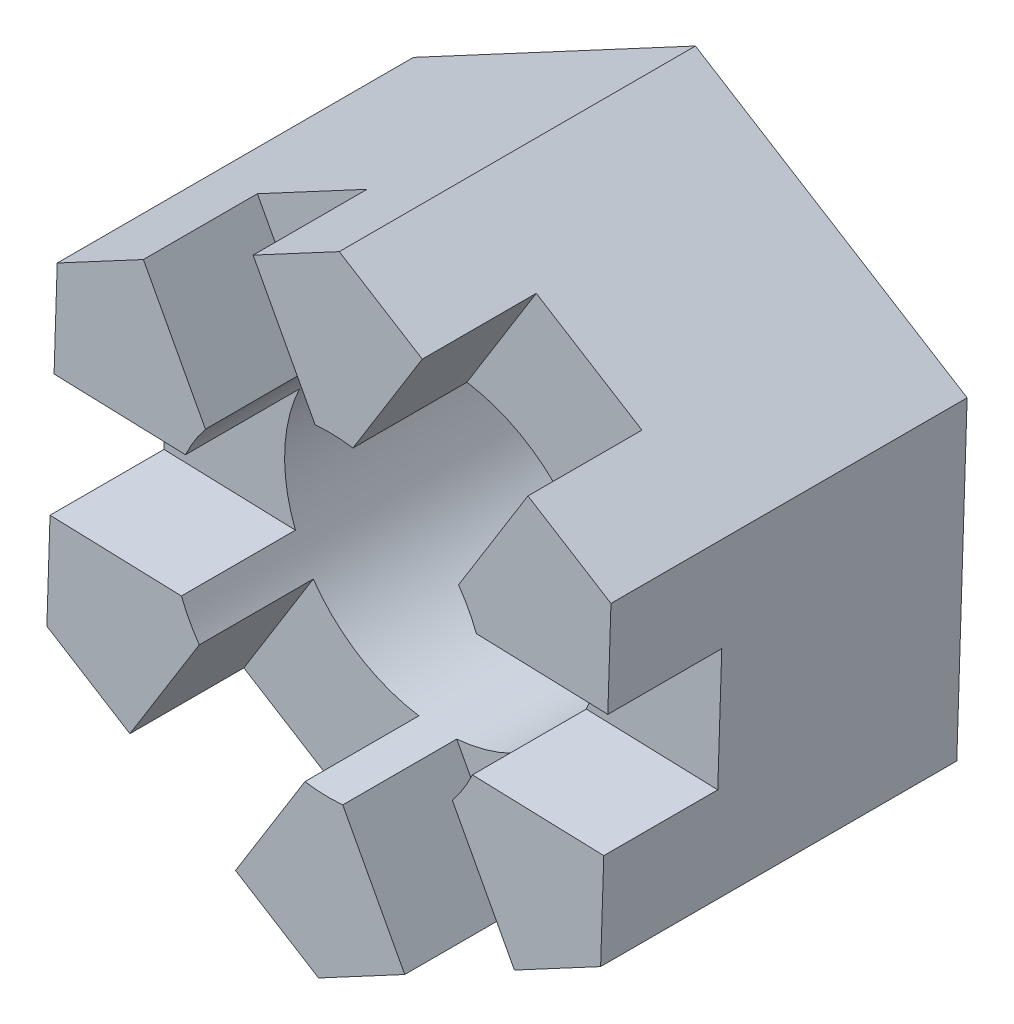
from build123d import *

# Parameters (mm, degrees)
SKETCH1_R         = 3.175
EXTRUDE1_DEPTH    = 7.14375
EXTRUDE2_DEPTH    = 2.286
CIRPATTERN1_COUNT = 3


with BuildPart() as part:
    # Sketch1 → Extrude1 (new body)
    with BuildSketch(Plane.XY):
        Polygon((5.657191877, 3.026339728), (0.207708854, 6.412441744), (-5.449483023, 3.386102016), (-5.657191877, -3.026339728), (-0.207708854, -6.412441744), (5.449483023, -3.386102016), align=None)
        Circle(SKETCH1_R, mode=Mode.SUBTRACT)
    extrude(amount=EXTRUDE1_DEPTH)

    # Sketch2 → Extrude2 (cut)
    with BuildSketch(Plane.XY.offset(7.14375)):
        Polygon((-4.410852186, -4.735268522), (2.291891507, 6.051910302), (4.410852186, 4.735268522), (-2.291891507, -6.051910302), align=None)
    extrude2 = extrude(amount=-EXTRUDE2_DEPTH, mode=Mode.SUBTRACT)

    # CirPattern1: Extrude2 ×3 about axis
    cirpattern1_axis = Axis((0, 0, 0), (0, 0, 1))
    for i in range(1, CIRPATTERN1_COUNT):
        add(extrude2.rotate(cirpattern1_axis, i * 360 / CIRPATTERN1_COUNT), mode=Mode.SUBTRACT)


solid = part.part
